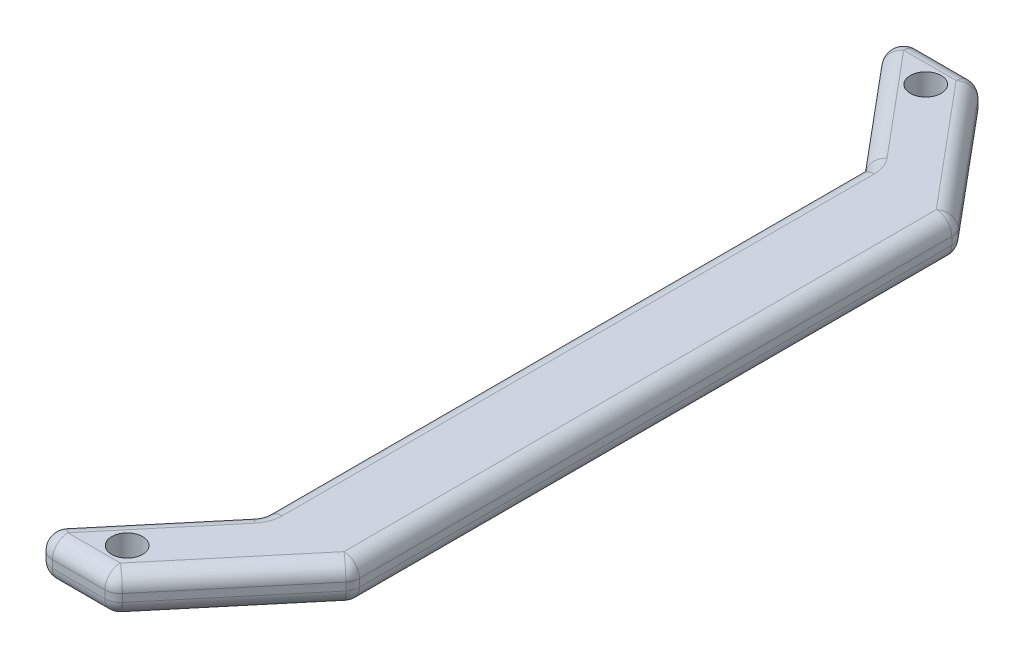
from build123d import *

# Parameters (mm, degrees)
BOSS_EXTRUDE1_DEPTH = 6.35
FILLET1_R           = 2.54
SKETCH2_R           = 2.54
CUT_EXTRUDE1_DEPTH  = 6.35


with BuildPart() as part:
    # Sketch1 → Boss-Extrude1 (new body)
    with BuildSketch(Plane(origin=(0, 0, 0), x_dir=(1, 0, 0), z_dir=(0, 1, 0))):
        Polygon((0, -49.53), (0, 49.53), (-18.074412074, 71.12), (-33.314412074, 71.12), (-15.24, 49.53), (-15.24, -49.53), (-33.314412074, -71.12), (-18.074412074, -71.12), align=None)
    extrude(amount=BOSS_EXTRUDE1_DEPTH)

    # Fillet1
    fillet1_edges = [part.edges().sort_by_distance(p)[0] for p in [
        (-15.24, 0, 0),
        (-24.277206037, 0, -60.325),
        (-25.694412074, 0, -71.12),
        (-9.037206037, 0, -60.325),
        (-24.277206037, 6.35, -60.325),
        (0, 3.175, -49.53),
        (0, 3.175, 49.53),
        (-18.074412074, 3.175, 71.12),
        (-33.314412074, 3.175, 71.12),
        (-15.24, 3.175, 49.53),
        (-15.24, 3.175, -49.53),
        (-33.314412074, 3.175, -71.12),
        (-18.074412074, 3.175, -71.12),
        (-15.24, 6.35, 0),
        (-24.277206037, 6.35, 60.325),
        (-25.694412074, 6.35, 71.12),
        (-9.037206037, 6.35, 60.325),
        (0, 6.35, 0),
        (-9.037206037, 6.35, -60.325),
        (0, 0, 0),
        (-25.694412074, 6.35, -71.12),
        (-9.037206037, 0, 60.325),
        (-25.694412074, 0, 71.12),
        (-24.277206037, 0, 60.325),
    ]]
    fillet(fillet1_edges, radius=FILLET1_R)

    # Sketch2 → Cut-Extrude1 (cut)
    with BuildSketch(Plane(origin=(0, 6.35, 0), x_dir=(1, 0, 0), z_dir=(0, 1, 0))):
        with Locations((-21.19842308, -65.532)):
            Circle(SKETCH2_R)
    cut_extrude1 = extrude(amount=-CUT_EXTRUDE1_DEPTH, mode=Mode.SUBTRACT)

    # Mirror1: Cut-Extrude1 across plane
    add(cut_extrude1.mirror(Plane.XY), mode=Mode.SUBTRACT)


solid = part.part
